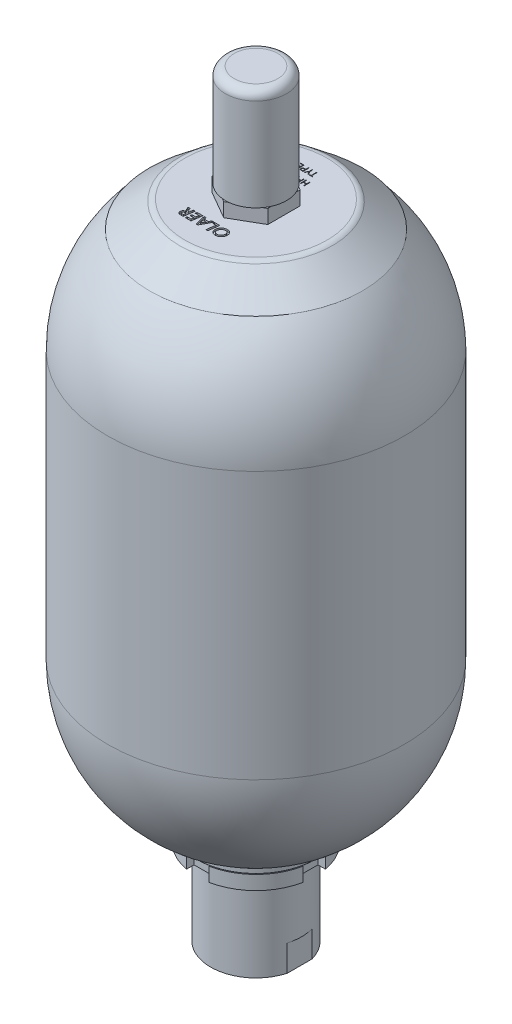
from build123d import *

# Parameters (mm, degrees)
SKETCH1_R                 = 26
BOSS_EXTRUDE1_DEPTH       = 65
G1_1_4_TAPPED_HOLE1_D     = 38.952
G1_1_4_TAPPED_HOLE1_DEPTH = 23
G1_1_4_TAPPED_HOLE1_TIP   = 11.702361416
SKETCH5_R                 = 18
CUT_EXTRUDE1_DEPTH        = 57
SKETCH6_OUTSIDE_W         = 73.63
SKETCH6_OUTSIDE_H         = 73.63
SKETCH6_OUTSIDE_W_2       = 50
SKETCH6_OUTSIDE_H_2       = 69.382104442
CUT_EXTRUDE2_DEPTH        = 15
SKETCH7_R                 = 5
CUT_EXTRUDE3_DEPTH        = 15
CIRPATTERN1_COUNT         = 6
BOSS_EXTRUDE2_DEPTH       = 8
SKETCH9_R                 = 3
BOSS_EXTRUDE3_DEPTH       = 5
SKETCH10_R                = 85
SKETCH10_R_2              = 20.61852266
BOSS_EXTRUDE4_DEPTH       = 303
SKETCH11_R                = 34
SKETCH11_R_2              = 19.850962615
BOSS_EXTRUDE5_DEPTH       = 8
CHAMFER1_SIZE             = 0.5
SKETCH12_R                = 34
SKETCH12_R_2              = 19.545737919
BOSS_EXTRUDE6_DEPTH       = 8
SKETCH13_W                = 12.93333618
SKETCH13_H                = 20.301365313
CUT_EXTRUDE5_DEPTH        = 8
CIRPATTERN2_COUNT         = 4
SKETCH16_R                = 20.61852266
BOSS_EXTRUDE7_DEPTH       = 8
SKETCH17_R                = 42.5
BOSS_EXTRUDE8_DEPTH       = 15
BOSS_EXTRUDE8_TAPER       = -51
SKETCH18_R                = 17.5
BOSS_EXTRUDE9_DEPTH       = 66
FILLET2_R                 = 5
SKETCH19_OUTSIDE_W        = 271.228
SKETCH19_OUTSIDE_H        = 271.228
SKETCH19_OUTSIDE_R        = 16
CUT_EXTRUDE6_DEPTH        = 8
BOSS_EXTRUDE10_DEPTH      = 8
FILLET3_R                 = 5
SKETCH21_W                = 1.346153846
SKETCH21_H                = 0.358974359
CUT_EXTRUDE7_DEPTH        = 1
CUT_EXTRUDE8_DEPTH        = 1


with BuildPart() as part:
    # Sketch1 → Boss-Extrude1 (new body)
    with BuildSketch(Plane(origin=(0, 0, 0), x_dir=(1, 0, 0), z_dir=(0, 1, 0))):
        Circle(SKETCH1_R)
    extrude(amount=BOSS_EXTRUDE1_DEPTH)

    # G1-1/4 Tapped Hole1
    with Locations(Plane(origin=(0, 0, 0), x_dir=(-1, 0, 0), z_dir=(0, -1, 0))):
        with Locations((0, 0)):
            Hole(G1_1_4_TAPPED_HOLE1_D / 2, depth=G1_1_4_TAPPED_HOLE1_DEPTH)
            with Locations((0, 0, -(G1_1_4_TAPPED_HOLE1_DEPTH + G1_1_4_TAPPED_HOLE1_TIP / 2))):  # 118° drill point
                Cone(0, G1_1_4_TAPPED_HOLE1_D / 2, G1_1_4_TAPPED_HOLE1_TIP, mode=Mode.SUBTRACT)

    # Sketch5 → Cut-Extrude1 (cut)
    with BuildSketch(Plane.XZ):
        Circle(SKETCH5_R)
    extrude(amount=-CUT_EXTRUDE1_DEPTH, mode=Mode.SUBTRACT)

    # Sketch6 outside → Cut-Extrude2 (cut)
    with BuildSketch(Plane.XZ):
        Rectangle(SKETCH6_OUTSIDE_W, SKETCH6_OUTSIDE_H)
        Rectangle(SKETCH6_OUTSIDE_W_2, SKETCH6_OUTSIDE_H_2, mode=Mode.SUBTRACT)
    extrude(amount=-CUT_EXTRUDE2_DEPTH, mode=Mode.SUBTRACT)

    # Sketch7 → Cut-Extrude3 (cut)
    with BuildSketch(Plane(origin=(0, 57, 0), x_dir=(-1, 0, 0), z_dir=(0, -1, 0))):
        with Locations((-12, 0)):
            Circle(SKETCH7_R)
    cut_extrude3 = extrude(amount=-CUT_EXTRUDE3_DEPTH, mode=Mode.SUBTRACT)

    # CirPattern1: Cut-Extrude3 ×6 about axis
    cirpattern1_axis = Axis((0, 0, 0), (0, 1, 0))
    for i in range(1, CIRPATTERN1_COUNT):
        add(cut_extrude3.rotate(cirpattern1_axis, i * 360 / CIRPATTERN1_COUNT), mode=Mode.SUBTRACT)

    # Sketch8 → Boss-Extrude2 (add)
    with BuildSketch(Plane.XZ.offset(-57)):
        Polygon((5.773502692, 0), (2.886751346, 5), (-2.886751346, 5), (-5.773502692, 0), (-2.886751346, -5), (2.886751346, -5), align=None)
    extrude(amount=BOSS_EXTRUDE2_DEPTH)

    # Sketch9 → Boss-Extrude3 (add)
    with BuildSketch(Plane.XZ.offset(-49)):
        Circle(SKETCH9_R)
    extrude(amount=BOSS_EXTRUDE3_DEPTH)

    # Sketch10 → Boss-Extrude4 (add)
    with BuildSketch(Plane(origin=(0, 65, 0), x_dir=(1, 0, 0), z_dir=(0, 1, 0))):
        Circle(SKETCH10_R)
        Circle(SKETCH10_R_2, mode=Mode.SUBTRACT)
    extrude(amount=BOSS_EXTRUDE4_DEPTH)

    # Sketch11 → Boss-Extrude5 (add)
    with BuildSketch(Plane.XZ.offset(-65)):
        Circle(SKETCH11_R)
        Circle(SKETCH11_R_2, mode=Mode.SUBTRACT)
    extrude(amount=BOSS_EXTRUDE5_DEPTH)

    # Chamfer1
    chamfer1_edges = [part.edges().sort_by_distance(p)[0] for p in [
        (-34, 57, 0),
    ]]
    chamfer(chamfer1_edges, length=CHAMFER1_SIZE)

    # Sketch12 → Boss-Extrude6 (add)
    with BuildSketch(Plane.XZ.offset(-57)):
        Circle(SKETCH12_R)
        Circle(SKETCH12_R_2, mode=Mode.SUBTRACT)
    extrude(amount=BOSS_EXTRUDE6_DEPTH)

    # Sketch13 → Cut-Extrude5 (cut)
    with BuildSketch(Plane.XZ.offset(-49)):
        with Locations((0, 39.150682657)):
            Rectangle(SKETCH13_W, SKETCH13_H)
    cut_extrude5 = extrude(amount=-CUT_EXTRUDE5_DEPTH, mode=Mode.SUBTRACT)

    # CirPattern2: Cut-Extrude5 ×4 about axis
    cirpattern2_axis = Axis((0, 0, 0), (0, 1, 0))
    for i in range(1, CIRPATTERN2_COUNT):
        add(cut_extrude5.rotate(cirpattern2_axis, i * 360 / CIRPATTERN2_COUNT), mode=Mode.SUBTRACT)

    # Sketch15 → Cut-Revolve1 (revolve, cut)
    with BuildSketch(Plane(origin=(0, 0, 0), x_dir=(0, 0, -1), z_dir=(1, 0, 0))):
        with BuildLine():
            Line((40, 65), (85, 65))
            Line((85, 65), (85, 140))
            ThreePointArc((85, 140), (72.886898686, 96.267860789), (40, 65))
        make_face()
        with BuildLine():
            Line((85, 368), (85, 293))
            ThreePointArc((85, 293), (72.886898686, 336.732139211), (40, 368))
            Line((40, 368), (85, 368))
        make_face()
    revolve(axis=Axis((0, 107.8001618, 0), (0, 1, 0)), mode=Mode.SUBTRACT)

    # Sketch16 → Boss-Extrude7 (add)
    with BuildSketch(Plane(origin=(0, 368, 0), x_dir=(1, 0, 0), z_dir=(0, 1, 0))):
        Circle(SKETCH16_R)
    extrude(amount=-BOSS_EXTRUDE7_DEPTH)

    # Sketch17 → Boss-Extrude8 (add)
    with BuildSketch(Plane(origin=(0, 368, 0), x_dir=(1, 0, 0), z_dir=(0, 1, 0))):
        Circle(SKETCH17_R)
    extrude(amount=-BOSS_EXTRUDE8_DEPTH, taper=BOSS_EXTRUDE8_TAPER)

    # Sketch18 → Boss-Extrude9 (add)
    with BuildSketch(Plane(origin=(0, 368, 0), x_dir=(1, 0, 0), z_dir=(0, 1, 0))):
        Circle(SKETCH18_R)
    extrude(amount=BOSS_EXTRUDE9_DEPTH)

    # Fillet2
    fillet2_edges = [part.edges().sort_by_distance(p)[0] for p in [
        (-17.5, 434, 0),
    ]]
    fillet(fillet2_edges, radius=FILLET2_R)

    # Sketch19 outside → Cut-Extrude6 (cut)
    with BuildSketch(Plane(origin=(0, 368, 0), x_dir=(1, 0, 0), z_dir=(0, 1, 0))):
        Rectangle(SKETCH19_OUTSIDE_W, SKETCH19_OUTSIDE_H)
        Circle(SKETCH19_OUTSIDE_R, mode=Mode.SUBTRACT)
    extrude(amount=CUT_EXTRUDE6_DEPTH, mode=Mode.SUBTRACT)

    # Sketch20 → Boss-Extrude10 (add)
    with BuildSketch(Plane(origin=(0, 368, 0), x_dir=(1, 0, 0), z_dir=(0, 1, 0))):
        Polygon((0, 18.475208614), (-16, 9.237604307), (-16, -9.237604307), (0, -18.475208614), (16, -9.237604307), (16, 9.237604307), align=None)
    extrude(amount=BOSS_EXTRUDE10_DEPTH)

    # Fillet3
    fillet3_edges = [part.edges().sort_by_distance(p)[0] for p in [
        (-42.5, 368, 0),
    ]]
    fillet(fillet3_edges, radius=FILLET3_R)

    # Sketch21 → Cut-Extrude7 (cut)
    with BuildSketch(Plane(origin=(0, 368, 0), x_dir=(1, 0, 0), z_dir=(0, 1, 0))):
        Polygon((7.254964048, 20.393970092), (6.940861484, 20.393970092), (6.940861484, 21.829867528), (5.145989689, 21.829867528), (5.145989689, 20.393970092), (4.831887125, 20.393970092), (4.831887125, 23.893970092), (5.145989689, 23.893970092), (5.145989689, 22.188841887), (6.940861484, 22.188841887), (6.940861484, 23.893970092), (7.254964048, 23.893970092), align=None)
        with BuildLine():
            Line((3.934451228, 20.393970092), (3.248052991, 20.393970092))
            add(Edge.make_bspline(
                [(3.248052991, 20.393970092), (3.200842085, 20.394021988), (3.110383892, 20.394121424), (2.980668836, 20.39713617), (2.862859104, 20.401162862), (2.757208723, 20.406744755), (2.663392625, 20.413341345), (2.581835326, 20.422593385), (2.51189577, 20.43225368), (2.46998932, 20.442075087), (2.45087751, 20.446554227)],
                knots=[0, 0, 0, 0, 0.000141628, 0.000271366, 0.00038923, 0.000495248, 0.00058876, 0.000671296, 0.000741499, 0.00080036, 0.00080036, 0.00080036, 0.00080036], degree=3))
            add(Edge.make_bspline(
                [(2.45087751, 20.446554227), (2.42668413, 20.453176376), (2.378867456, 20.466264633), (2.309964189, 20.492475466), (2.244418601, 20.523568363), (2.181956518, 20.558952628), (2.123647988, 20.600299275), (2.067672506, 20.645221913), (2.01520396, 20.695537323), (1.967034608, 20.751179258), (1.922403623, 20.810324911), (1.885044289, 20.874482465), (1.852054527, 20.941426267), (1.826345306, 21.012790772), (1.80613687, 21.087633977), (1.791419044, 21.166150675), (1.781959583, 21.248171489), (1.781061999, 21.304233284), (1.780605074, 21.332772176)],
                knots=[0, 0, 0, 0, 7.5216e-05, 0.00014866, 0.000220794, 0.000292713, 0.000363707, 0.00043499, 0.000507883, 0.000581424, 0.000655604, 0.000729794, 0.000803798, 0.000879214, 0.00095694, 0.001036145, 0.001118681, 0.001204264, 0.001204264, 0.001204264, 0.001204264], degree=3))
            add(Edge.make_bspline(
                [(1.780605074, 21.332772176), (1.781026499, 21.361549952), (1.781851045, 21.417855616), (1.79174733, 21.500228404), (1.805077522, 21.578946795), (1.825574574, 21.653836245), (1.852420247, 21.724452016), (1.8839123, 21.791873248), (1.92189583, 21.854952919), (1.96554066, 21.913920037), (2.014092254, 21.968829949), (2.067345193, 22.019284744), (2.125084485, 22.064989082), (2.187126633, 22.106045426), (2.254076482, 22.141501705), (2.324918636, 22.17325901), (2.400268852, 22.199930071), (2.452411366, 22.213960132), (2.478922382, 22.22109349)],
                knots=[0, 0, 0, 0, 8.6284e-05, 0.00016882, 0.000248587, 0.000325638, 0.000401297, 0.000474998, 0.000548586, 0.000621785, 0.0006948, 0.0007682, 0.000841564, 0.000915458, 0.000991056, 0.00106858, 0.00114819, 0.001230532, 0.001230532, 0.001230532, 0.001230532], degree=3))
            add(Edge.make_bspline(
                [(2.478922382, 22.22109349), (2.500849965, 22.225752996), (2.54890554, 22.235964574), (2.6280433, 22.247442101), (2.720229922, 22.256854928), (2.825151747, 22.265639054), (2.94305345, 22.270293542), (3.073664621, 22.275758671), (3.217427293, 22.278337366), (3.317697274, 22.278500372), (3.370048183, 22.278585477)],
                knots=[0, 0, 0, 0, 6.7238e-05, 0.000147357, 0.000239727, 0.000345231, 0.000463153, 0.000593654, 0.000737411, 0.000894464, 0.000894464, 0.000894464, 0.000894464], degree=3))
            Line((3.370048183, 22.278585477), (3.620348664, 22.278585477))
            Line((3.620348664, 22.278585477), (3.620348664, 23.893970092))
            Line((3.620348664, 23.893970092), (3.934451228, 23.893970092))
            Line((3.934451228, 23.893970092), (3.934451228, 20.393970092))
        make_face()
        with BuildLine():
            Line((3.620348664, 20.752944451), (3.620348664, 21.919611118))
            Line((3.620348664, 21.919611118), (3.007568215, 21.927323458))
            add(Edge.make_bspline(
                [(3.007568215, 21.927323458), (2.977647786, 21.927343186), (2.919887013, 21.927381272), (2.836224514, 21.923327711), (2.758791883, 21.918917894), (2.687474795, 21.911786173), (2.622598759, 21.903087696), (2.564006702, 21.891457789), (2.51123103, 21.879596035), (2.450439302, 21.859013786), (2.382346191, 21.827962852), (2.308441051, 21.781584411), (2.245295169, 21.723159238), (2.19111297, 21.656758421), (2.148285642, 21.582812499), (2.11724682, 21.503914336), (2.098301368, 21.420363522), (2.095920086, 21.363252777), (2.094707638, 21.334174419)],
                knots=[0, 0, 0, 0, 8.9746e-05, 0.000173253, 0.000251233, 0.000322392, 0.00038823, 0.000447495, 0.000501572, 0.000550349, 0.000639766, 0.000725536, 0.0008109, 0.000896638, 0.000981777, 0.001066145, 0.001150177, 0.001237345, 0.001237345, 0.001237345, 0.001237345], degree=3))
            add(Edge.make_bspline(
                [(2.094707638, 21.334174419), (2.095974178, 21.30603812), (2.098491902, 21.250106639), (2.117090324, 21.168095211), (2.148614352, 21.090093998), (2.191147885, 21.016734166), (2.244031688, 20.950509833), (2.305921729, 20.893386743), (2.375855094, 20.847152289), (2.440400683, 20.816374454), (2.498163902, 20.798325646), (2.548094952, 20.785295321), (2.604759055, 20.776308583), (2.667619957, 20.767709964), (2.736597176, 20.760769008), (2.812129322, 20.755948986), (2.893964803, 20.75315767), (2.950775107, 20.753017245), (2.980224465, 20.752944451)],
                knots=[0, 0, 0, 0, 8.4371e-05, 0.000167719, 0.000250783, 0.000335923, 0.000421221, 0.000504087, 0.000587508, 0.000671882, 0.000717558, 0.000768912, 0.000826545, 0.000889509, 0.000959274, 0.001034454, 0.001116533, 0.001204877, 0.001204877, 0.001204877, 0.001204877], degree=3))
            Line((2.980224465, 20.752944451), (3.620348664, 20.752944451))
        make_face(mode=Mode.SUBTRACT)
        with BuildLine():
            Line((1.062656356, 20.393970092), (0.379763728, 20.393970092))
            add(Edge.make_bspline(
                [(0.379763728, 20.393970092), (0.346334722, 20.394143076), (0.28154099, 20.394478361), (0.187328713, 20.399799094), (0.099055083, 20.406872505), (0.016876091, 20.418737772), (-0.05974299, 20.431040489), (-0.130024315, 20.449097932), (-0.194556578, 20.469043036), (-0.272046617, 20.499731285), (-0.359969684, 20.547390522), (-0.45447053, 20.618073699), (-0.536616431, 20.702817121), (-0.606464796, 20.799388936), (-0.662519595, 20.905628874), (-0.70255973, 21.019251152), (-0.728283037, 21.138344208), (-0.730895262, 21.21999351), (-0.732215439, 21.261257752)],
                knots=[0, 0, 0, 0, 0.00010027, 0.000194349, 0.000283026, 0.000365821, 0.000443395, 0.000515665, 0.000583297, 0.000645921, 0.000765443, 0.00088211, 0.000998625, 0.001118112, 0.001238542, 0.001357628, 0.001478632, 0.00160227, 0.00160227, 0.00160227, 0.00160227], degree=3))
            add(Edge.make_bspline(
                [(-0.732215439, 21.261257752), (-0.7311371, 21.299915244), (-0.729018063, 21.375880861), (-0.708316781, 21.486616889), (-0.677068698, 21.59235987), (-0.631975816, 21.692090761), (-0.574478603, 21.784933231), (-0.504524603, 21.869303623), (-0.421578331, 21.943545471), (-0.359301813, 21.984862115), (-0.327668163, 22.005849099)],
                knots=[0, 0, 0, 0, 0.000115857, 0.00022767, 0.000336798, 0.000446002, 0.000554953, 0.000663485, 0.000773706, 0.000887491, 0.000887491, 0.000887491, 0.000887491], degree=3))
            add(Edge.make_bspline(
                [(-0.327668163, 22.005849099), (-0.367431412, 22.021107253), (-0.443508359, 22.050299883), (-0.54833554, 22.10211201), (-0.638681739, 22.158033675), (-0.715711273, 22.218474768), (-0.78025658, 22.28540886), (-0.837756131, 22.357073199), (-0.886554232, 22.43596361), (-0.928189899, 22.520370575), (-0.961171964, 22.609847106), (-0.984066103, 22.703723812), (-0.998585639, 22.80093741), (-1.000484333, 22.86700884), (-1.001446208, 22.900480509)],
                knots=[0, 0, 0, 0, 0.000127722, 0.000244363, 0.000350193, 0.000446003, 0.00053723, 0.000628551, 0.000721152, 0.000814906, 0.000910508, 0.001006585, 0.001104351, 0.001204731, 0.001204731, 0.001204731, 0.001204731], degree=3))
            add(Edge.make_bspline(
                [(-1.001446208, 22.900480509), (-1.000469268, 22.934647324), (-0.998547112, 23.00187149), (-0.984368479, 23.100627437), (-0.96035445, 23.1949994), (-0.927301413, 23.285615559), (-0.884215114, 23.371945203), (-0.832162387, 23.454666787), (-0.769688136, 23.532554363), (-0.699335985, 23.606738177), (-0.620843225, 23.674576071), (-0.534350345, 23.732873726), (-0.442074067, 23.783227807), (-0.342750778, 23.823709664), (-0.237085244, 23.855399553), (-0.125052712, 23.87730989), (-0.006716797, 23.892132371), (0.074494133, 23.893347124), (0.116141933, 23.893970092)],
                knots=[0, 0, 0, 0, 0.000102481, 0.000201635, 0.000298562, 0.000394165, 0.000490425, 0.000587487, 0.000686802, 0.000789456, 0.000893869, 0.000997324, 0.001101793, 0.001208689, 0.001318487, 0.001432201, 0.001550821, 0.001675692, 0.001675692, 0.001675692, 0.001675692], degree=3))
            Line((0.116141933, 23.893970092), (1.062656356, 23.893970092))
            Line((1.062656356, 23.893970092), (1.062656356, 20.393970092))
        make_face()
        with BuildLine():
            Line((0.748553792, 20.752944451), (0.748553792, 21.874739323))
            Line((0.748553792, 21.874739323), (0.537516132, 21.874739323))
            add(Edge.make_bspline(
                [(0.537516132, 21.874739323), (0.506667059, 21.874342728), (0.447060362, 21.873576426), (0.360511072, 21.871312147), (0.28037375, 21.865249712), (0.206372275, 21.858837675), (0.13900258, 21.848964493), (0.078039316, 21.836882363), (0.022934238, 21.824216514), (-0.040583245, 21.802614036), (-0.112622963, 21.771022032), (-0.188881648, 21.720793235), (-0.257517893, 21.662639147), (-0.314138834, 21.593659311), (-0.361277822, 21.519167327), (-0.393014672, 21.438607705), (-0.415142784, 21.354756552), (-0.417112703, 21.29692846), (-0.418112875, 21.267567849)],
                knots=[0, 0, 0, 0, 9.2559e-05, 0.000178842, 0.000259666, 0.000333617, 0.000401637, 0.000463788, 0.000520074, 0.000571069, 0.000664896, 0.000755131, 0.000844107, 0.000933698, 0.001021841, 0.001107381, 0.001192575, 0.001280442, 0.001280442, 0.001280442, 0.001280442], degree=3))
            add(Edge.make_bspline(
                [(-0.418112875, 21.267567849), (-0.417625075, 21.248130483), (-0.416668202, 21.210001967), (-0.407647384, 21.154450909), (-0.395198763, 21.101588256), (-0.374667886, 21.052839091), (-0.350344104, 21.00649163), (-0.319166825, 20.964009903), (-0.283216554, 20.924243075), (-0.241303043, 20.888257057), (-0.193597627, 20.855709781), (-0.138589111, 20.828615727), (-0.077773042, 20.804537572), (-0.009881215, 20.786285767), (0.063734026, 20.770440294), (0.144195789, 20.760448227), (0.231019156, 20.754029165), (0.291175756, 20.753314087), (0.322271741, 20.752944451)],
                knots=[0, 0, 0, 0, 5.8261e-05, 0.000114285, 0.00016853, 0.000220739, 0.000272498, 0.000325232, 0.000378337, 0.000433016, 0.000490576, 0.000551092, 0.000616582, 0.000686501, 0.000761718, 0.000842335, 0.000929502, 0.001022775, 0.001022775, 0.001022775, 0.001022775], degree=3))
            Line((0.322271741, 20.752944451), (0.748553792, 20.752944451))
        make_face(mode=Mode.SUBTRACT)
        with BuildLine():
            Line((0.748553792, 22.233713682), (0.748553792, 23.534995733))
            Line((0.748553792, 23.534995733), (0.301238087, 23.534995733))
            add(Edge.make_bspline(
                [(0.301238087, 23.534995733), (0.269222362, 23.534575086), (0.207516272, 23.533764343), (0.118355502, 23.531840562), (0.036156095, 23.524703343), (-0.039766344, 23.517860618), (-0.109060529, 23.506681604), (-0.172400464, 23.495856462), (-0.228339437, 23.479926731), (-0.293791265, 23.458007138), (-0.366998477, 23.422976724), (-0.446944207, 23.371461499), (-0.517359765, 23.308712159), (-0.577102432, 23.236459855), (-0.62677584, 23.158710331), (-0.661140029, 23.07531056), (-0.683406066, 22.989046231), (-0.686028476, 22.930061847), (-0.687343644, 22.900480509)],
                knots=[0, 0, 0, 0, 9.6064e-05, 0.000185151, 0.000267424, 0.000343537, 0.00041374, 0.000477957, 0.000536129, 0.000588012, 0.000684924, 0.000778657, 0.000872516, 0.000966594, 0.001059196, 0.00114813, 0.001236215, 0.001324834, 0.001324834, 0.001324834, 0.001324834], degree=3))
            add(Edge.make_bspline(
                [(-0.687343644, 22.900480509), (-0.687075178, 22.881984395), (-0.686542576, 22.84529051), (-0.678170604, 22.79141513), (-0.666552449, 22.738968978), (-0.649430551, 22.688664447), (-0.628717711, 22.6396353), (-0.601392197, 22.593476858), (-0.570569219, 22.548224226), (-0.522829089, 22.4903411), (-0.452443757, 22.424455001), (-0.352388524, 22.360754458), (-0.239258336, 22.308549878), (-0.157012969, 22.286480393), (-0.114527138, 22.275079868)],
                knots=[0, 0, 0, 0, 5.5429e-05, 0.000109963, 0.000163198, 0.000216409, 0.000269161, 0.000322557, 0.00037701, 0.000433297, 0.000547392, 0.000664463, 0.000787767, 0.000919525, 0.000919525, 0.000919525, 0.000919525], degree=3))
            add(Edge.make_bspline(
                [(-0.114527138, 22.275079868), (-0.097498058, 22.271624552), (-0.0605755, 22.264132713), (-0.000367613, 22.256229476), (0.06859874, 22.249140015), (0.146028786, 22.244033622), (0.232230473, 22.238551999), (0.32717611, 22.236496056), (0.430932818, 22.233986669), (0.502925278, 22.233807005), (0.540320619, 22.233713682)],
                knots=[0, 0, 0, 0, 5.2115e-05, 0.000112995, 0.000182062, 0.000260088, 0.000345766, 0.00044116, 0.000544947, 0.000657129, 0.000657129, 0.000657129, 0.000657129], degree=3))
            Line((0.540320619, 22.233713682), (0.748553792, 22.233713682))
        make_face(mode=Mode.SUBTRACT)
        with Locations((-2.078369285, 22.547816247)):
            Rectangle(SKETCH21_W, SKETCH21_H)
        Polygon((-4.931233868, 20.304226502), (-4.995035952, 20.304226502), (-4.995035952, 22.727303426), (-5.398882105, 22.727303426), (-5.398882105, 23.086277785), (-4.995035952, 23.086277785), (-4.995035952, 23.893970092), (-4.680933388, 23.893970092), (-4.680933388, 23.086277785), (-3.020676977, 23.086277785), align=None)
        Polygon((-4.680933388, 22.727303426), (-4.680933388, 21.207271374), (-3.637664157, 22.727303426), align=None, mode=Mode.SUBTRACT)
        Polygon((-6.027087234, 20.393970092), (-6.341189798, 20.393970092), (-6.341189798, 23.534995733), (-7.687343644, 23.534995733), (-7.687343644, 23.893970092), (-6.027087234, 23.893970092), align=None)
        Polygon((5.101117895, 27.54140599), (5.101117895, 27.182431631), (3.261374305, 27.182431631), (3.261374305, 27.54140599), (4.024194818, 27.54140599), (4.024194818, 30.682431631), (4.338297382, 30.682431631), (4.338297382, 27.54140599), align=None)
        Polygon((2.902399946, 27.182431631), (2.542724465, 27.182431631), (1.62285267, 28.686337881), (0.704383119, 27.182431631), (0.344707638, 27.182431631), (1.46650251, 29.018669611), (1.46650251, 30.682431631), (1.780605074, 30.682431631), (1.780605074, 29.018669611), align=None)
        with BuildLine():
            Line((-0.238625695, 27.182431631), (-0.925023932, 27.182431631))
            add(Edge.make_bspline(
                [(-0.925023932, 27.182431631), (-0.972234839, 27.182483527), (-1.062693031, 27.182582962), (-1.192408087, 27.185597708), (-1.310217819, 27.1896244), (-1.4158682, 27.195206294), (-1.509684298, 27.201802884), (-1.591241597, 27.211054923), (-1.661181154, 27.220715219), (-1.703087603, 27.230536625), (-1.722199413, 27.235015765)],
                knots=[0, 0, 0, 0, 0.000141628, 0.000271366, 0.00038923, 0.000495248, 0.00058876, 0.000671296, 0.000741499, 0.00080036, 0.00080036, 0.00080036, 0.00080036], degree=3))
            add(Edge.make_bspline(
                [(-1.722199413, 27.235015765), (-1.746392793, 27.241637915), (-1.794209467, 27.254726171), (-1.863112734, 27.280937004), (-1.928658323, 27.312029901), (-1.991120405, 27.347414167), (-2.049428935, 27.388760813), (-2.105404417, 27.433683452), (-2.157872963, 27.483998861), (-2.206042315, 27.539640797), (-2.2506733, 27.59878645), (-2.288032634, 27.662944003), (-2.321022396, 27.729887806), (-2.346731617, 27.801252311), (-2.366940053, 27.876095515), (-2.381657879, 27.954612214), (-2.39111734, 28.036633027), (-2.392014924, 28.092694822), (-2.392471849, 28.121233714)],
                knots=[0, 0, 0, 0, 7.5216e-05, 0.00014866, 0.000220794, 0.000292713, 0.000363707, 0.00043499, 0.000507883, 0.000581424, 0.000655604, 0.000729794, 0.000803798, 0.000879214, 0.00095694, 0.001036145, 0.001118681, 0.001204264, 0.001204264, 0.001204264, 0.001204264], degree=3))
            add(Edge.make_bspline(
                [(-2.392471849, 28.121233714), (-2.392050424, 28.150011491), (-2.391225878, 28.206317155), (-2.381329593, 28.288689943), (-2.367999401, 28.367408333), (-2.347502349, 28.442297784), (-2.320656676, 28.512913554), (-2.289164623, 28.580334786), (-2.251181093, 28.643414458), (-2.207536263, 28.702381575), (-2.158984669, 28.757291488), (-2.105731731, 28.807746282), (-2.047992438, 28.853450621), (-1.98595029, 28.894506964), (-1.919000441, 28.929963244), (-1.848158288, 28.961720549), (-1.772808071, 28.988391609), (-1.720665557, 29.002421671), (-1.694154541, 29.009555028)],
                knots=[0, 0, 0, 0, 8.6284e-05, 0.00016882, 0.000248587, 0.000325638, 0.000401297, 0.000474998, 0.000548586, 0.000621785, 0.0006948, 0.0007682, 0.000841564, 0.000915458, 0.000991056, 0.00106858, 0.00114819, 0.001230532, 0.001230532, 0.001230532, 0.001230532], degree=3))
            add(Edge.make_bspline(
                [(-1.694154541, 29.009555028), (-1.672226958, 29.014214534), (-1.624171383, 29.024426112), (-1.545033623, 29.03590364), (-1.452847001, 29.045316467), (-1.347925176, 29.054100592), (-1.230023473, 29.058755081), (-1.099412302, 29.064220209), (-0.95564963, 29.066798905), (-0.855379649, 29.06696191), (-0.80302874, 29.067047015)],
                knots=[0, 0, 0, 0, 6.7238e-05, 0.000147357, 0.000239727, 0.000345231, 0.000463153, 0.000593654, 0.000737411, 0.000894464, 0.000894464, 0.000894464, 0.000894464], degree=3))
            Line((-0.80302874, 29.067047015), (-0.552728259, 29.067047015))
            Line((-0.552728259, 29.067047015), (-0.552728259, 30.682431631))
            Line((-0.552728259, 30.682431631), (-0.238625695, 30.682431631))
            Line((-0.238625695, 30.682431631), (-0.238625695, 27.182431631))
        make_face()
        with BuildLine():
            Line((-0.552728259, 27.54140599), (-0.552728259, 28.708072656))
            Line((-0.552728259, 28.708072656), (-1.165508708, 28.715784996))
            add(Edge.make_bspline(
                [(-1.165508708, 28.715784996), (-1.195429137, 28.715804725), (-1.25318991, 28.71584281), (-1.336852409, 28.71178925), (-1.41428504, 28.707379433), (-1.485602128, 28.700247711), (-1.550478164, 28.691549234), (-1.609070221, 28.679919327), (-1.661845893, 28.668057573), (-1.722637621, 28.647475325), (-1.790730732, 28.616424391), (-1.864635872, 28.57004595), (-1.927781754, 28.511620776), (-1.981963953, 28.44521996), (-2.024791281, 28.371274037), (-2.055830103, 28.292375874), (-2.074775555, 28.20882506), (-2.077156837, 28.151714315), (-2.078369285, 28.122635958)],
                knots=[0, 0, 0, 0, 8.9746e-05, 0.000173253, 0.000251233, 0.000322392, 0.00038823, 0.000447495, 0.000501572, 0.000550349, 0.000639766, 0.000725536, 0.0008109, 0.000896638, 0.000981777, 0.001066145, 0.001150177, 0.001237345, 0.001237345, 0.001237345, 0.001237345], degree=3))
            add(Edge.make_bspline(
                [(-2.078369285, 28.122635958), (-2.077102745, 28.094499658), (-2.074585021, 28.038568178), (-2.055986599, 27.95655675), (-2.024462571, 27.878555536), (-1.981929038, 27.805195704), (-1.929045235, 27.738971372), (-1.867155194, 27.681848281), (-1.797221829, 27.635613827), (-1.73267624, 27.604835992), (-1.674913021, 27.586787185), (-1.624981971, 27.573756859), (-1.568317868, 27.564770121), (-1.505456966, 27.556171503), (-1.436479747, 27.549230547), (-1.360947601, 27.544410525), (-1.27911212, 27.541619208), (-1.222301816, 27.541478783), (-1.192852458, 27.54140599)],
                knots=[0, 0, 0, 0, 8.4371e-05, 0.000167719, 0.000250783, 0.000335923, 0.000421221, 0.000504087, 0.000587508, 0.000671882, 0.000717558, 0.000768912, 0.000826545, 0.000889509, 0.000959274, 0.001034454, 0.001116533, 0.001204877, 0.001204877, 0.001204877, 0.001204877], degree=3))
            Line((-1.192852458, 27.54140599), (-0.552728259, 27.54140599))
        make_face(mode=Mode.SUBTRACT)
        Polygon((-3.110420567, 27.182431631), (-5.084779541, 27.182431631), (-5.084779541, 27.54140599), (-3.424523131, 27.54140599), (-3.424523131, 28.618329067), (-5.084779541, 28.618329067), (-5.084779541, 28.977303426), (-3.424523131, 28.977303426), (-3.424523131, 30.323457272), (-5.084779541, 30.323457272), (-5.084779541, 30.682431631), (-3.110420567, 30.682431631), align=None)
    extrude(amount=-CUT_EXTRUDE7_DEPTH, mode=Mode.SUBTRACT)

    # Sketch22 → Cut-Extrude8 (cut)
    with BuildSketch(Plane(origin=(0, 368, 0), x_dir=(1, 0, 0), z_dir=(0, 1, 0))):
        with BuildLine():
            add(Edge.make_bspline(
                [(6.193095894, -29.60311107), (6.092013685, -29.600989036), (5.893541773, -29.596822485), (5.6026184, -29.558499558), (5.325094307, -29.496686128), (5.061540316, -29.408203595), (4.811512376, -29.295951915), (4.57398414, -29.159679292), (4.351469824, -28.996417768), (4.144308514, -28.810678006), (3.956096063, -28.605942975), (3.790970627, -28.385951614), (3.651195983, -28.152005046), (3.538488963, -27.904142081), (3.448324326, -27.643637093), (3.387206622, -27.368970365), (3.346781631, -27.081879744), (3.342906081, -26.885706074), (3.340932432, -26.785803377)],
                knots=[0, 0, 0, 0, 0.000303123, 0.000595173, 0.000878592, 0.001154912, 0.001427666, 0.001699591, 0.001974855, 0.002254037, 0.002533054, 0.002807814, 0.003077843, 0.003348906, 0.003623334, 0.003903237, 0.004191869, 0.004491389, 0.004491389, 0.004491389, 0.004491389], degree=3))
            add(Edge.make_bspline(
                [(3.340932432, -26.785803377), (3.342197441, -26.708020683), (3.344713445, -26.553316933), (3.368657131, -26.323288759), (3.40595181, -26.096522449), (3.457040019, -25.872964865), (3.525341511, -25.653287029), (3.606996705, -25.436857479), (3.703178657, -25.223377003), (3.815027078, -25.015610768), (3.937624908, -24.814266257), (4.072617196, -24.624268408), (4.217064085, -24.445964016), (4.37073585, -24.279556031), (4.535447172, -24.126701245), (4.708029898, -23.984232458), (4.892210345, -23.855383588), (5.085063127, -23.737676158), (5.287009904, -23.633122047), (5.496612924, -23.542544124), (5.713978837, -23.467567337), (5.937368033, -23.402615727), (6.169464315, -23.355417555), (6.408165601, -23.320390634), (6.654671534, -23.299736657), (6.82126287, -23.296872705), (6.905836279, -23.295418762)],
                knots=[0, 0, 0, 0, 0.000233285, 0.000463985, 0.000692998, 0.000922452, 0.001151323, 0.001382592, 0.001616053, 0.001853186, 0.002090038, 0.002322814, 0.002551824, 0.002778054, 0.003001705, 0.003225469, 0.003448888, 0.003675427, 0.00390282, 0.004130555, 0.004359769, 0.004592226, 0.00482795, 0.005069659, 0.005315701, 0.005569409, 0.005569409, 0.005569409, 0.005569409], degree=3))
            add(Edge.make_bspline(
                [(6.905836279, -23.295418762), (7.010492298, -23.297760905), (7.214797796, -23.302333148), (7.513100516, -23.33696224), (7.794499959, -23.397579714), (8.060582446, -23.480045905), (8.310175564, -23.587495582), (8.544505528, -23.717806067), (8.761257395, -23.873733578), (8.960580216, -24.051844226), (9.140814009, -24.248282103), (9.297920787, -24.461695796), (9.429616392, -24.691086001), (9.538154099, -24.934666641), (9.622645749, -25.193677941), (9.68207825, -25.467500851), (9.719089329, -25.756344849), (9.72336228, -25.953958395), (9.725547817, -26.055034147)],
                knots=[0, 0, 0, 0, 0.000313932, 0.000612846, 0.00089927, 0.001176393, 0.001447213, 0.001713034, 0.001979202, 0.002246505, 0.002513635, 0.00277759, 0.003039825, 0.003305621, 0.003576243, 0.00385562, 0.004145134, 0.004448257, 0.004448257, 0.004448257, 0.004448257], degree=3))
            add(Edge.make_bspline(
                [(9.725547817, -26.055034147), (9.722930763, -26.170571978), (9.717777645, -26.398072145), (9.672333136, -26.732922019), (9.603294412, -27.055877709), (9.500264849, -27.365464069), (9.372292442, -27.663556997), (9.213128737, -27.948343584), (9.027037601, -28.222075097), (8.881898541, -28.390506733), (8.808480509, -28.475707223)],
                knots=[0, 0, 0, 0, 0.000346454, 0.000682187, 0.001012016, 0.001335849, 0.001659383, 0.001983806, 0.002313188, 0.002650363, 0.002650363, 0.002650363, 0.002650363], degree=3))
            add(Edge.make_bspline(
                [(8.808480509, -28.475707223), (8.76574413, -28.521903328), (8.681040828, -28.613463788), (8.545478183, -28.740702987), (8.406598095, -28.859832078), (8.262429935, -28.969426183), (8.11516873, -29.072070303), (7.962402238, -29.164384317), (7.805421002, -29.247661546), (7.644122628, -29.322297427), (7.477981262, -29.388387095), (7.307606966, -29.446242118), (7.132504606, -29.494222279), (6.953185004, -29.533830343), (6.769539288, -29.565351573), (6.581306298, -29.586499617), (6.388810965, -29.600187049), (6.258824544, -29.602129071), (6.193095894, -29.60311107)],
                knots=[0, 0, 0, 0, 0.000188744, 0.00037409, 0.000557386, 0.000737442, 0.000917144, 0.001095653, 0.001272548, 0.00145001, 0.001628564, 0.001808724, 0.001989512, 0.002172939, 0.002359469, 0.002548213, 0.002740975, 0.002938149, 0.002938149, 0.002938149, 0.002938149], degree=3))
        make_face()
        with BuildLine():
            add(Edge.make_bspline(
                [(6.218336279, -28.60311107), (6.272862732, -28.602296276), (6.381342682, -28.60067525), (6.54190312, -28.584360799), (6.699243635, -28.559111096), (6.852655287, -28.524407329), (7.002691248, -28.480089575), (7.148395415, -28.423890684), (7.291631769, -28.359878091), (7.429394813, -28.283327697), (7.563359344, -28.199683124), (7.690477446, -28.105788037), (7.811517983, -28.003141655), (7.925004769, -27.891369774), (8.033107156, -27.772078436), (8.132418337, -27.642743824), (8.226745428, -27.505372321), (8.313418299, -27.359832927), (8.392453622, -27.20954089), (8.46112374, -27.056617079), (8.51914302, -26.902518206), (8.56577439, -26.746956005), (8.603579324, -26.590593882), (8.629834392, -26.432749984), (8.646126184, -26.273731186), (8.647791008, -26.16725229), (8.64862474, -26.113928377)],
                knots=[0, 0, 0, 0, 0.000163532, 0.000325346, 0.000483622, 0.000641367, 0.000796899, 0.000952486, 0.001109552, 0.001267156, 0.001424882, 0.001583062, 0.001740807, 0.001900595, 0.0020606, 0.002223362, 0.002389384, 0.002560264, 0.002731225, 0.002898539, 0.003062846, 0.003224825, 0.003385456, 0.003545113, 0.003704535, 0.003864463, 0.003864463, 0.003864463, 0.003864463], degree=3))
            add(Edge.make_bspline(
                [(8.64862474, -26.113928377), (8.647257951, -26.051771254), (8.644568718, -25.929473709), (8.622724476, -25.749146089), (8.585093948, -25.576481183), (8.535207615, -25.41017), (8.468041383, -25.252672264), (8.389006066, -25.10100637), (8.293079044, -24.957902244), (8.184566075, -24.822330633), (8.06214191, -24.698069667), (7.926158831, -24.589263334), (7.776254334, -24.498659515), (7.614396287, -24.4234854), (7.439038945, -24.366584231), (7.251736471, -24.323828518), (7.051464461, -24.300396647), (6.913906093, -24.297106608), (6.843336279, -24.295418762)],
                knots=[0, 0, 0, 0, 0.000186438, 0.000366826, 0.000543868, 0.000716096, 0.000886862, 0.001056759, 0.001228436, 0.001402819, 0.001577048, 0.001750679, 0.001923831, 0.002101293, 0.002284872, 0.002475861, 0.002676823, 0.002888529, 0.002888529, 0.002888529, 0.002888529], degree=3))
            add(Edge.make_bspline(
                [(6.843336279, -24.295418762), (6.760696041, -24.297381937), (6.597514196, -24.301258433), (6.357761994, -24.335448533), (6.127997404, -24.39298151), (5.90634311, -24.468949013), (5.695568013, -24.571340893), (5.493436518, -24.694288761), (5.301972576, -24.84084387), (5.122138764, -25.006928246), (4.95664486, -25.187705443), (4.813651908, -25.382190582), (4.690738547, -25.58532308), (4.590865126, -25.798442286), (4.513495452, -26.021296583), (4.458365228, -26.253602313), (4.423568857, -26.495486469), (4.419776114, -26.66028424), (4.417855509, -26.74373607)],
                knots=[0, 0, 0, 0, 0.000247832, 0.000489371, 0.00072462, 0.000957635, 0.001190947, 0.001426147, 0.001666297, 0.001912975, 0.00215973, 0.002400361, 0.002635965, 0.002870934, 0.003105084, 0.003342384, 0.003586303, 0.003836537, 0.003836537, 0.003836537, 0.003836537], degree=3))
            add(Edge.make_bspline(
                [(4.417855509, -26.74373607), (4.418948575, -26.812330404), (4.421090737, -26.94675982), (4.446374615, -27.142421385), (4.48373758, -27.328327225), (4.540070018, -27.50294873), (4.608842336, -27.66835202), (4.695456637, -27.822297009), (4.796580784, -27.965980625), (4.913144399, -28.098116473), (5.042658957, -28.216165004), (5.181384484, -28.321251708), (5.331357494, -28.40738273), (5.490404649, -28.478961507), (5.658547904, -28.53554912), (5.836964155, -28.575356525), (6.024649778, -28.597816221), (6.15297319, -28.601324225), (6.218336279, -28.60311107)],
                knots=[0, 0, 0, 0, 0.000205655, 0.000403038, 0.000590911, 0.00077375, 0.000952562, 0.001127441, 0.001302514, 0.001478787, 0.00165488, 0.001827476, 0.001999817, 0.002172501, 0.00235, 0.00253108, 0.002719965, 0.002916059, 0.002916059, 0.002916059, 0.002916059], degree=3))
        make_face(mode=Mode.SUBTRACT)
        Polygon((1.884201663, -29.449264916), (0.796461279, -29.449264916), (1.498384355, -24.449264916), (-0.35137526, -24.449264916), (-0.221567568, -23.449264916), (2.725547817, -23.449264916), align=None)
        Polygon((-3.806904106, -29.449264916), (-4.751615645, -29.449264916), (-6.274452183, -23.449264916), (-5.166279106, -23.449264916), (-4.834548337, -24.756957223), (-2.495606029, -24.756957223), (-1.793682952, -23.449264916), (-0.582144491, -23.449264916), align=None)
        Polygon((-4.578538721, -25.756957223), (-4.083346414, -27.710082223), (-3.034067568, -25.756957223), align=None, mode=Mode.SUBTRACT)
        Polygon((-7.808106029, -29.449264916), (-11.043682952, -29.449264916), (-10.917481029, -28.449264916), (-8.755221414, -28.449264916), (-8.560509875, -27.064649531), (-10.743202183, -27.064649531), (-10.615798337, -26.064649531), (-8.419884875, -26.064649531), (-8.193923337, -24.449264916), (-10.412673337, -24.449264916), (-10.286471414, -23.449264916), (-6.966759875, -23.449264916), align=None)
        with BuildLine():
            Line((-12.269644491, -29.449264916), (-13.311711798, -29.449264916))
            add(Edge.make_bspline(
                [(-13.311711798, -29.449264916), (-13.389044458, -29.448948891), (-13.538151123, -29.448339556), (-13.752571357, -29.439674825), (-13.949372654, -29.426602415), (-14.128321008, -29.409350781), (-14.289565824, -29.385415104), (-14.432771782, -29.356675529), (-14.558853571, -29.324670007), (-14.634464375, -29.294928389), (-14.669884875, -29.280995685)],
                knots=[0, 0, 0, 0, 0.000231984, 0.000447292, 0.000643651, 0.000823643, 0.000986485, 0.001132394, 0.001261845, 0.001375932, 0.001375932, 0.001375932, 0.001375932], degree=3))
            add(Edge.make_bspline(
                [(-14.669884875, -29.280995685), (-14.709765298, -29.26301392), (-14.787725212, -29.227862415), (-14.899412017, -29.168248438), (-15.004094711, -29.10414318), (-15.099834543, -29.032422024), (-15.189559983, -28.958463573), (-15.270614086, -28.877944357), (-15.34521736, -28.793304418), (-15.411344129, -28.702412347), (-15.470671972, -28.607545714), (-15.520991472, -28.507637584), (-15.56329772, -28.403431411), (-15.597845661, -28.295273385), (-15.626138177, -28.18300087), (-15.644542013, -28.066319245), (-15.65746295, -27.945548533), (-15.658526551, -27.863563795), (-15.659067568, -27.82186107)],
                knots=[0, 0, 0, 0, 0.000131208, 0.000256491, 0.000379563, 0.000499038, 0.000615072, 0.00072811, 0.000841404, 0.000953189, 0.001064923, 0.001176728, 0.001288325, 0.001401975, 0.001517122, 0.001635284, 0.001756076, 0.001881128, 0.001881128, 0.001881128, 0.001881128], degree=3))
            add(Edge.make_bspline(
                [(-15.659067568, -27.82186107), (-15.657794947, -27.77054345), (-15.655282589, -27.66923416), (-15.638912902, -27.519827037), (-15.608245673, -27.376505129), (-15.567499682, -27.238942124), (-15.515528134, -27.106884688), (-15.451848904, -26.980359165), (-15.37528402, -26.859606536), (-15.287864915, -26.744020873), (-15.187807717, -26.636014), (-15.07651129, -26.535166875), (-14.952640771, -26.444172431), (-14.816561545, -26.362433853), (-14.67006627, -26.287247217), (-14.51018766, -26.223388611), (-14.339742609, -26.164504329), (-14.220237225, -26.135026449), (-14.159067568, -26.119937993)],
                knots=[0, 0, 0, 0, 0.000153963, 0.000303949, 0.0004501, 0.000593083, 0.000733919, 0.000875287, 0.001017342, 0.001162298, 0.001309449, 0.001458375, 0.001612226, 0.00176971, 0.001934194, 0.00210561, 0.00228577, 0.002474683, 0.002474683, 0.002474683, 0.002474683], degree=3))
            Line((-14.159067568, -26.119937993), (-15.543682952, -23.449264916))
            Line((-15.543682952, -23.449264916), (-14.340557952, -23.449264916))
            Line((-14.340557952, -23.449264916), (-12.984788721, -26.064649531))
            Line((-12.984788721, -26.064649531), (-12.88262526, -26.064649531))
            Line((-12.88262526, -26.064649531), (-12.514836798, -23.449264916))
            Line((-12.514836798, -23.449264916), (-11.428298337, -23.449264916))
            Line((-11.428298337, -23.449264916), (-12.269644491, -29.449264916))
        make_face()
        with BuildLine():
            add(Edge.make_bspline(
                [(-13.02325026, -27.064649531), (-13.100585645, -27.065366075), (-13.248508781, -27.066736643), (-13.459765967, -27.076310718), (-13.650292811, -27.091337034), (-13.819447393, -27.113111157), (-13.968063875, -27.13799529), (-14.094525005, -27.171807275), (-14.200658789, -27.20931663), (-14.287450609, -27.25420647), (-14.357200786, -27.307047992), (-14.418839527, -27.362008907), (-14.46902177, -27.425065129), (-14.510871601, -27.493617533), (-14.543072242, -27.56807125), (-14.566314046, -27.648803054), (-14.579159938, -27.73530986), (-14.581135185, -27.794977873), (-14.582144491, -27.825466839)],
                knots=[0, 0, 0, 0, 0.000231999, 0.000443756, 0.000634302, 0.000805148, 0.000955331, 0.001085943, 0.001197359, 0.001292524, 0.001377623, 0.001459283, 0.001539623, 0.001618365, 0.001699644, 0.001782193, 0.001869735, 0.001961208, 0.001961208, 0.001961208, 0.001961208], degree=3))
            add(Edge.make_bspline(
                [(-14.582144491, -27.825466839), (-14.581011338, -27.860083125), (-14.57881018, -27.927325529), (-14.554499639, -28.023213927), (-14.519225892, -28.111552017), (-14.466180293, -28.189542233), (-14.399427967, -28.256957887), (-14.319707864, -28.314828444), (-14.226194676, -28.359544244), (-14.138408735, -28.389483671), (-14.055625438, -28.406242698), (-13.978246671, -28.41812439), (-13.885929003, -28.42715639), (-13.779774883, -28.435821792), (-13.659095106, -28.441162786), (-13.524493654, -28.446409877), (-13.375417727, -28.448270022), (-13.271246673, -28.448923246), (-13.216759875, -28.449264916)],
                knots=[0, 0, 0, 0, 0.000103617, 0.000201276, 0.000295026, 0.000387699, 0.00048204, 0.000578449, 0.000681654, 0.000791877, 0.000855761, 0.000934805, 0.001026656, 0.001133957, 0.001254299, 0.001389001, 0.001538059, 0.001701525, 0.001701525, 0.001701525, 0.001701525], degree=3))
            Line((-13.216759875, -28.449264916), (-13.02325026, -27.064649531))
        make_face(mode=Mode.SUBTRACT)
    extrude(amount=-CUT_EXTRUDE8_DEPTH, mode=Mode.SUBTRACT)


solid = part.part
